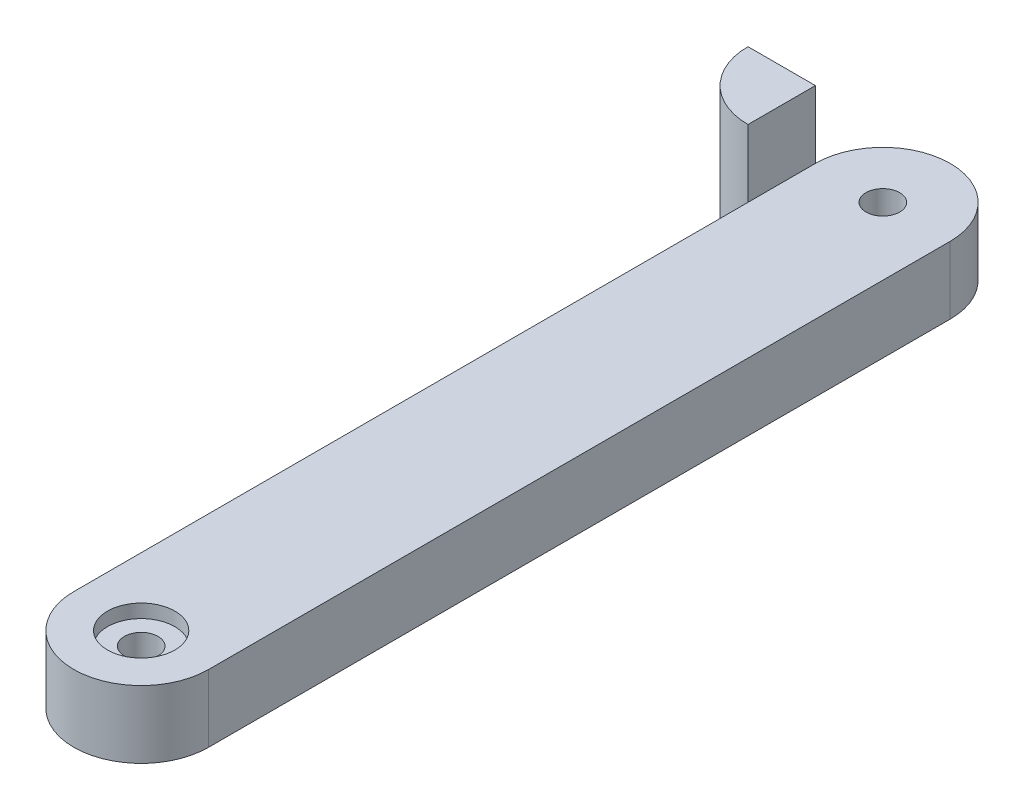
from build123d import *

# Parameters (mm, degrees)
BOSS_EXTRUDE2_DEPTH = 10
SKETCH2_R           = 2.5
CUT_EXTRUDE1_DEPTH  = 10
SKETCH3_W           = 10
SKETCH3_H           = 10
REVOLVE1_ANGLE      = 90
BOSS_EXTRUDE3_DEPTH = 10
SKETCH5_W           = 10
SKETCH5_H           = 10
REVOLVE2_ANGLE      = 90
SKETCH7_R           = 5
CUT_EXTRUDE2_DEPTH  = 2
SKETCH8_R           = 5
CUT_EXTRUDE3_DEPTH  = 2


with BuildPart() as part:
    # Sketch1 → Boss-Extrude2 (new body)
    with BuildSketch(Plane(origin=(0, 0, 0), x_dir=(1, 0, 0), z_dir=(0, 1, 0))):
        with BuildLine():
            ThreePointArc((10, 110), (0, 120), (-10, 110))
            Line((-10, 110), (10, 110))
        make_face()
        with BuildLine():
            Line((10, 110), (-10, 110))
            ThreePointArc((-10, 110), (0, 100), (10, 110))
        make_face()
        with BuildLine():
            Line((-10, 110), (-10, 0))
            ThreePointArc((-10, 0), (0, 10), (10, 0))
            Line((10, 0), (10, 110))
            ThreePointArc((10, 110), (0, 100), (-10, 110))
        make_face()
        with BuildLine():
            ThreePointArc((10, 0), (0, 10), (-10, 0))
            Line((-10, 0), (10, 0))
        make_face()
        with BuildLine():
            Line((10, 0), (-10, 0))
            ThreePointArc((-10, 0), (0, -10), (10, 0))
        make_face()
    extrude(amount=BOSS_EXTRUDE2_DEPTH)

    # Sketch2 → Cut-Extrude1 (cut)
    with BuildSketch(Plane(origin=(0, 10, 0), x_dir=(1, 0, 0), z_dir=(0, 1, 0))):
        Circle(SKETCH2_R)
        with Locations((0, 110)):
            Circle(SKETCH2_R)
    extrude(amount=-CUT_EXTRUDE1_DEPTH, mode=Mode.SUBTRACT)

    # Sketch3 → Revolve1 (revolve)
    with BuildSketch(Plane.ZY.offset(10)):
        with Locations((-105, 5)):
            Rectangle(SKETCH3_W, SKETCH3_H)
    revolve(axis=Axis((-10, 10, -110), (0, -1, 0)), revolution_arc=REVOLVE1_ANGLE)

    # Sketch4 → Boss-Extrude3 (add)
    with BuildSketch(Plane(origin=(0, 10, 0), x_dir=(1, 0, 0), z_dir=(0, 1, 0))):
        Polygon((-10, 110), (-10, 100), (-20, 110), align=None)
    extrude(amount=BOSS_EXTRUDE3_DEPTH)

    # Sketch5 → Revolve2 (revolve)
    with BuildSketch(Plane(origin=(-10, 0, 0), x_dir=(0, 0, -1), z_dir=(1, 0, 0))):
        with Locations((105, 15)):
            Rectangle(SKETCH5_W, SKETCH5_H)
    revolve(axis=Axis((-10, 20, -110), (0, -1, 0)), revolution_arc=REVOLVE2_ANGLE)

    # Sketch7 → Cut-Extrude2 (cut)
    with BuildSketch(Plane(origin=(0, 10, 0), x_dir=(1, 0, 0), z_dir=(0, 1, 0))):
        Circle(SKETCH7_R)
    extrude(amount=-CUT_EXTRUDE2_DEPTH, mode=Mode.SUBTRACT)

    # Sketch8 → Cut-Extrude3 (cut)
    with BuildSketch(Plane.XZ):
        with Locations((0, -110)):
            Circle(SKETCH8_R)
    extrude(amount=-CUT_EXTRUDE3_DEPTH, mode=Mode.SUBTRACT)


solid = part.part
